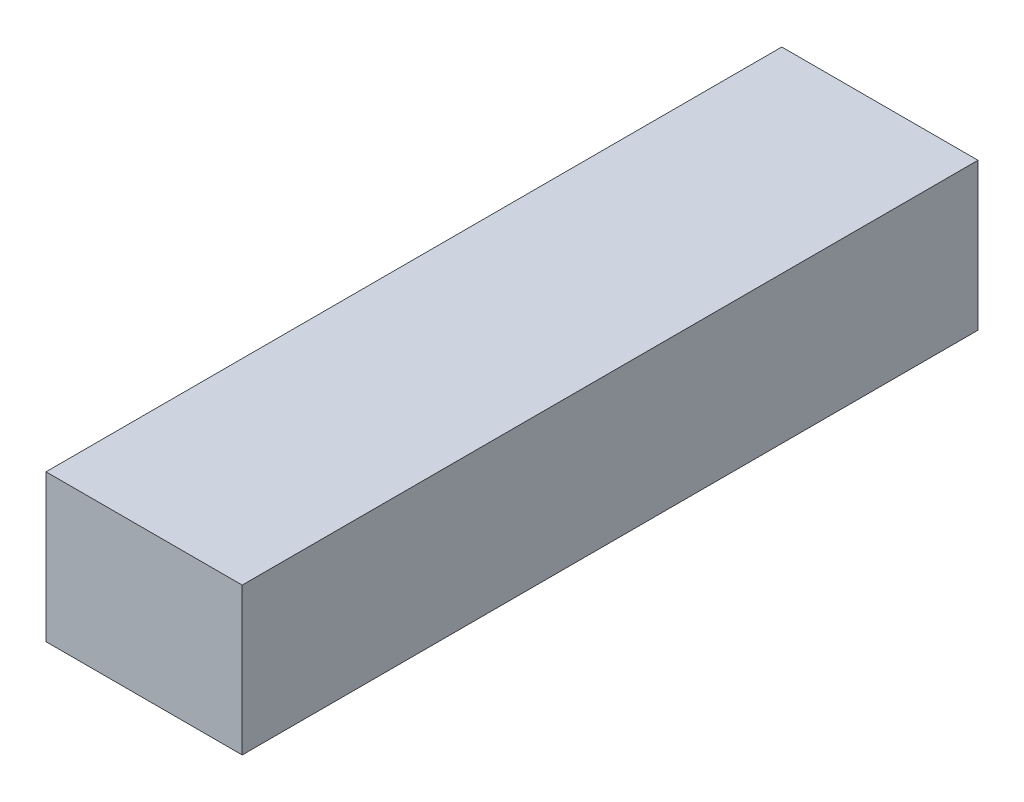
from build123d import *

# Parameters (mm, degrees)
SKETCH_1_W      = 40
SKETCH_1_H      = 150
EXTRUDE_1_DEPTH = 30


with BuildPart() as part:
    # Эскиз1 → Бобышка-Вытянуть1 (new body)
    with BuildSketch(Plane(origin=(0, 0, 0), x_dir=(1, 0, 0), z_dir=(0, 1, 0))):
        Rectangle(SKETCH_1_W, SKETCH_1_H)
    extrude(amount=EXTRUDE_1_DEPTH)


solid = part.part
